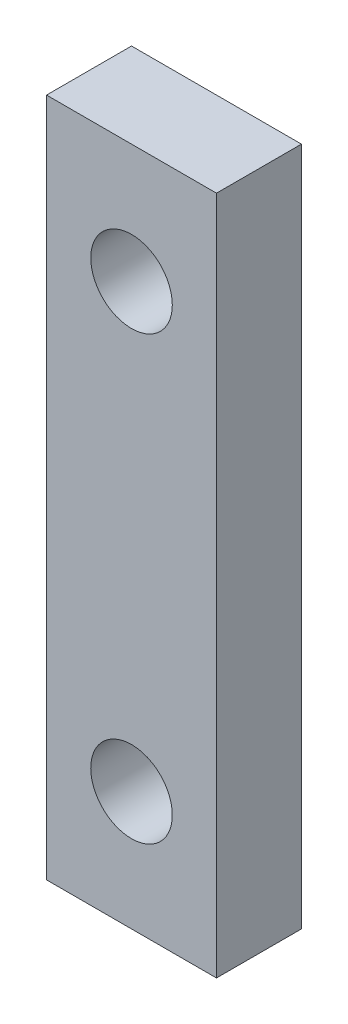
from build123d import *

# Parameters (mm, degrees)
SKETCH1_W           = 10
SKETCH1_H           = 40
SKETCH1_R           = 2.4
BOSS_EXTRUDE1_DEPTH = 5


with BuildPart() as part:
    # Sketch1 → Boss-Extrude1 (new body)
    with BuildSketch(Plane.XY):
        Rectangle(SKETCH1_W, SKETCH1_H)
        with Locations((0, 13)):
            Circle(SKETCH1_R, mode=Mode.SUBTRACT)
        with Locations((0, -13)):
            Circle(SKETCH1_R, mode=Mode.SUBTRACT)
    extrude(amount=BOSS_EXTRUDE1_DEPTH)


solid = part.part
